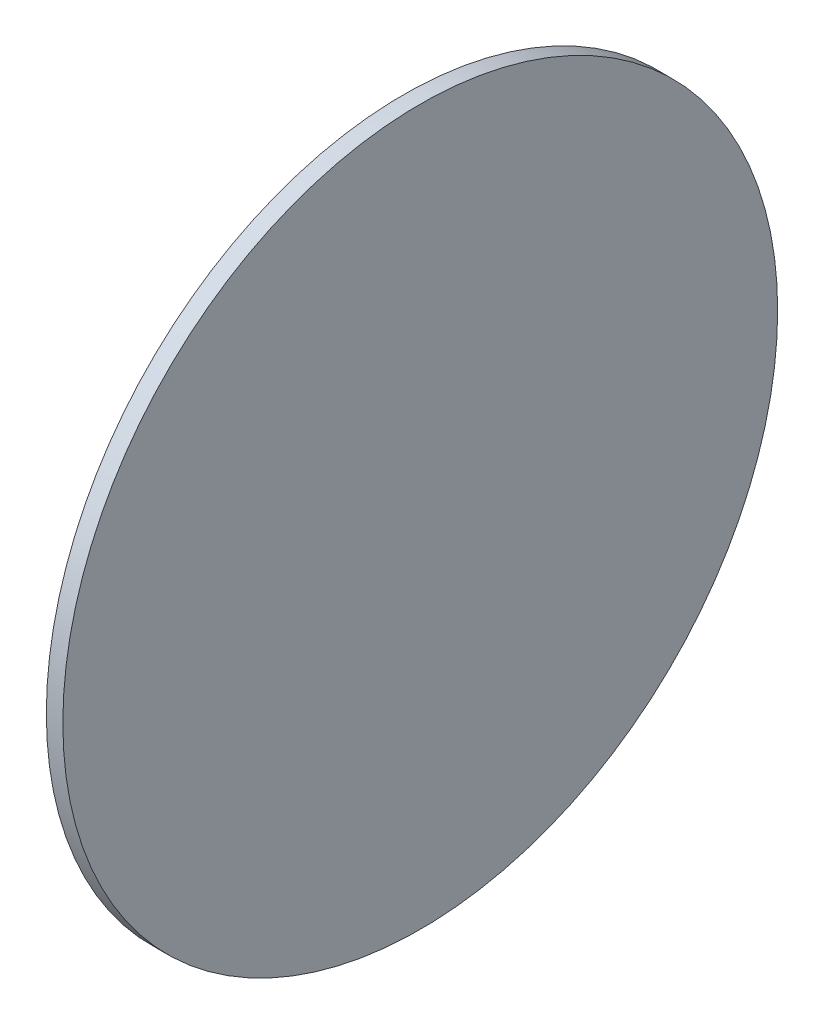
from build123d import *

# Parameters (mm, degrees)
SKETCH1_R           = 65
BOSS_EXTRUDE1_DEPTH = 3


with BuildPart() as part:
    # Sketch1 → Boss-Extrude1 (new body)
    with BuildSketch(Plane.ZY):
        Circle(SKETCH1_R)
    extrude(amount=-BOSS_EXTRUDE1_DEPTH)


solid = part.part
